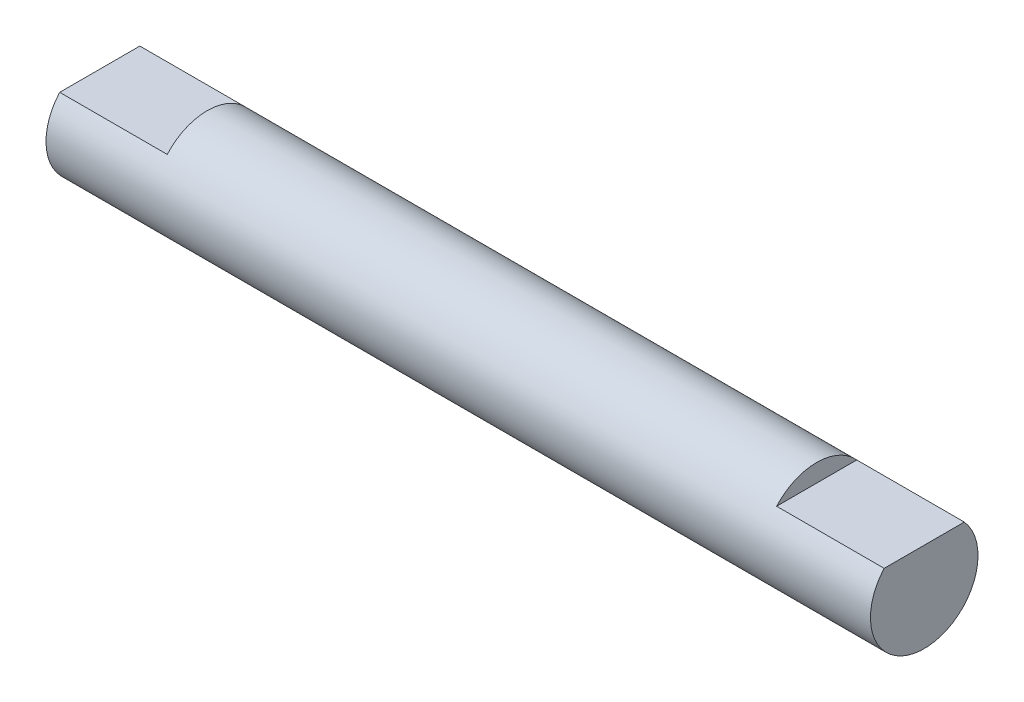
from build123d import *

# Parameters (mm, degrees)
SKETCH2_W          = 46
SKETCH2_H          = 3
CUT_EXTRUDE1_DEPTH = 6
CUT_EXTRUDE2_DEPTH = 6


with BuildPart() as part:
    # Sketch2 → Revolve1 (revolve)
    with BuildSketch(Plane.XY):
        with Locations((23, -1.5)):
            Rectangle(SKETCH2_W, SKETCH2_H)
    revolve(axis=Axis((0, 0, 0), (1, 0, 0)))

    # Sketch3 → Cut-Extrude1 (cut)
    with BuildSketch(Plane(origin=(46, 0, 0), x_dir=(0, 0, -1), z_dir=(1, 0, 0))):
        with BuildLine():
            Line((-2.236067977, 2), (2.236067977, 2))
            ThreePointArc((2.236067977, 2), (0, 3), (-2.236067977, 2))
        make_face()
    extrude(amount=-CUT_EXTRUDE1_DEPTH, mode=Mode.SUBTRACT)

    # Sketch4 → Cut-Extrude2 (cut)
    with BuildSketch(Plane.ZY):
        with BuildLine():
            Line((-2.236067977, 2), (2.236067977, 2))
            ThreePointArc((2.236067977, 2), (0, 3), (-2.236067977, 2))
        make_face()
    extrude(amount=-CUT_EXTRUDE2_DEPTH, mode=Mode.SUBTRACT)


solid = part.part
